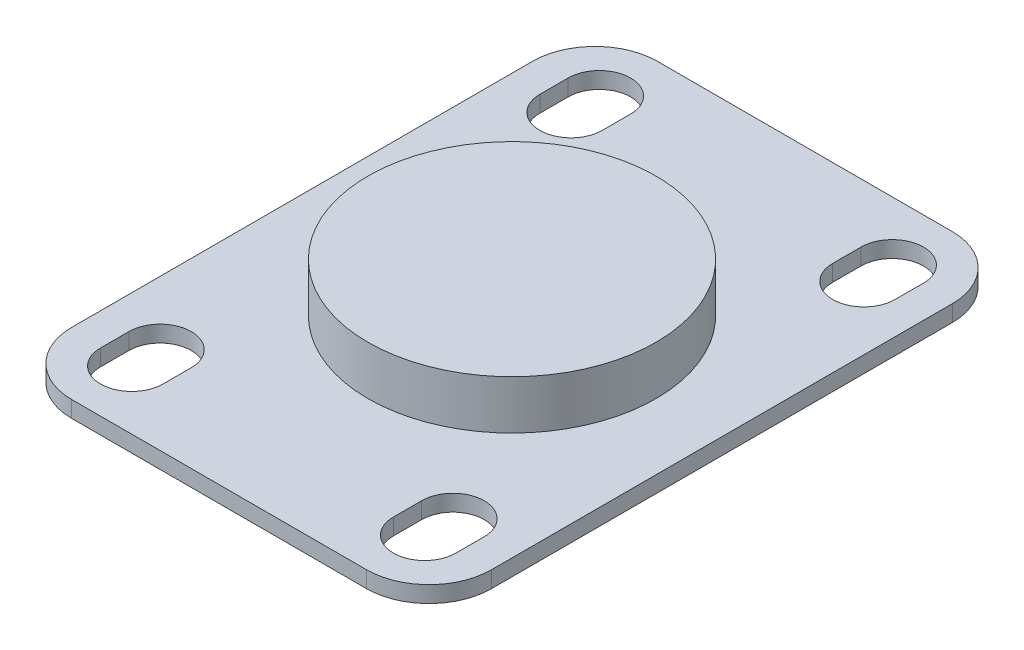
from build123d import *

# Parameters (mm, degrees)
EXTRUDE_1_DEPTH = 1.68
SKETCH_2_R      = 14.75
EXTRUDE_3_DEPTH = 5


with BuildPart() as part:
    # 草图1 → 凸台-拉伸1 (new body)
    with BuildSketch(Plane(origin=(0, 0, 0), x_dir=(1, 0, 0), z_dir=(0, 1, 0))):
        with BuildLine():
            ThreePointArc((-21.5, 23.6), (-19.6254834, 28.1254834), (-15.1, 30))
            Line((-15.1, 30), (15.1, 30))
            ThreePointArc((15.1, 30), (19.6254834, 28.1254834), (21.5, 23.6))
            Line((21.5, 23.6), (21.5, -23.6))
            ThreePointArc((21.5, -23.6), (19.6254834, -28.1254834), (15.1, -30))
            Line((15.1, -30), (-15.1, -30))
            ThreePointArc((-15.1, -30), (-19.6254834, -28.1254834), (-21.5, -23.6))
            Line((-21.5, -23.6), (-21.5, 23.6))
        make_face()
        with BuildLine():
            ThreePointArc((-18.2, -23.95), (-15, -27.15), (-11.8, -23.95))
            Line((-11.8, -23.95), (-11.8, -21.05))
            ThreePointArc((-11.8, -21.05), (-15, -17.85), (-18.2, -21.05))
            Line((-18.2, -21.05), (-18.2, -23.95))
        make_face(mode=Mode.SUBTRACT)
        with BuildLine():
            ThreePointArc((18.2, -21.05), (15, -17.85), (11.8, -21.05))
            Line((11.8, -21.05), (11.8, -23.95))
            ThreePointArc((11.8, -23.95), (15, -27.15), (18.2, -23.95))
            Line((18.2, -23.95), (18.2, -21.05))
        make_face(mode=Mode.SUBTRACT)
        with BuildLine():
            ThreePointArc((18.2, 23.95), (15, 27.15), (11.8, 23.95))
            Line((11.8, 23.95), (11.8, 21.05))
            ThreePointArc((11.8, 21.05), (15, 17.85), (18.2, 21.05))
            Line((18.2, 21.05), (18.2, 23.95))
        make_face(mode=Mode.SUBTRACT)
        with BuildLine():
            ThreePointArc((-18.2, 21.05), (-15, 17.85), (-11.8, 21.05))
            Line((-11.8, 21.05), (-11.8, 23.95))
            ThreePointArc((-11.8, 23.95), (-15, 27.15), (-18.2, 23.95))
            Line((-18.2, 23.95), (-18.2, 21.05))
        make_face(mode=Mode.SUBTRACT)
    extrude(amount=EXTRUDE_1_DEPTH)

    # 草图2 → 凸台-拉伸3 (add)
    with BuildSketch(Plane(origin=(0, 1.68, 0), x_dir=(1, 0, 0), z_dir=(0, 1, 0))):
        Circle(SKETCH_2_R)
    extrude(amount=EXTRUDE_3_DEPTH)


solid = part.part
